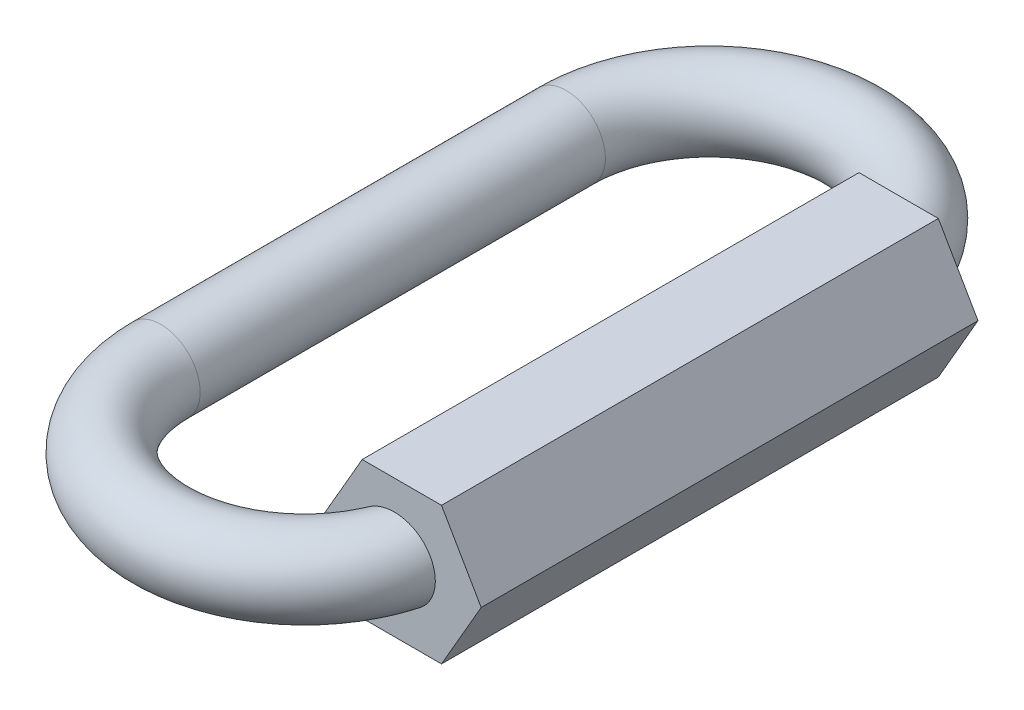
from build123d import *

# Parameters (mm, degrees)
SKETCH1_R                = 2.53
BOSS_EXTRUDE1_DEPTH      = 16
BOSS_EXTRUDE1_DEPTH_BACK = 16


with BuildPart() as part:
    # Sweep1: sweep along a path in Sketch2
    with BuildLine(Plane(origin=(0, 0, 0), x_dir=(1, 0, 0), z_dir=(0, 1, 0))) as sweep1_path:
        Line((0, -13.05), (0, 13.05))
        ThreePointArc((0, 13.05), (-9.235, 22.285), (-18.47, 13.05))
        Line((-18.47, 13.05), (-18.47, -13.05))
        ThreePointArc((-18.47, -13.05), (-9.235, -22.285), (0, -13.05))
    # Sketch1 → Sweep1 (sweep)
    with BuildSketch(Plane.XY):
        Circle(SKETCH1_R)
    sweep(path=sweep1_path.line)

    # Sketch3 → Boss-Extrude1 (add, two sides: drawn at the far end of the back side and taken through both)
    with BuildSketch(Plane.XY.offset(-BOSS_EXTRUDE1_DEPTH_BACK)):
        Polygon((-2.554774941, 4.425), (-5.109549882, 0), (-2.554774941, -4.425), (2.554774941, -4.425), (5.109549882, 0), (2.554774941, 4.425), align=None)
    extrude(amount=BOSS_EXTRUDE1_DEPTH + BOSS_EXTRUDE1_DEPTH_BACK)


solid = part.part
